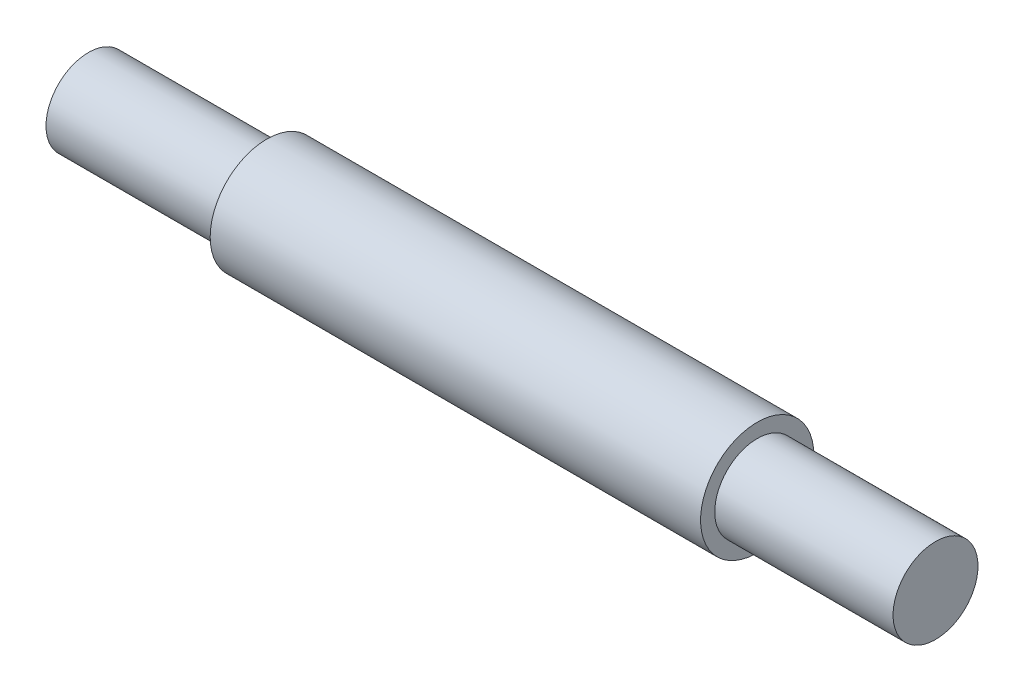
from build123d import *

# Parameters (mm, degrees)
SKETCH1_R                = 6.35
BOSS_EXTRUDE1_DEPTH      = 55
BOSS_EXTRUDE1_DEPTH_BACK = 40
SKETCH2_OUTSIDE_W        = 34.036
SKETCH2_OUTSIDE_H        = 34.036
SKETCH2_OUTSIDE_R        = 4.7625
CUT_EXTRUDE1_DEPTH       = 20
SKETCH3_OUTSIDE_W        = 34.036
SKETCH3_OUTSIDE_H        = 34.036
SKETCH3_OUTSIDE_R        = 4.7625
CUT_EXTRUDE2_DEPTH       = 20


with BuildPart() as part:
    # Sketch1 → Boss-Extrude1 (new body, two sides)
    with BuildSketch(Plane(origin=(0, 0, 0), x_dir=(0, 0, -1), z_dir=(1, 0, 0))) as boss_extrude1_sk:
        Circle(SKETCH1_R)
    extrude(amount=BOSS_EXTRUDE1_DEPTH)
    extrude(boss_extrude1_sk.sketch, amount=-BOSS_EXTRUDE1_DEPTH_BACK)

    # Sketch2 outside → Cut-Extrude1 (cut)
    with BuildSketch(Plane.ZY.offset(40)):
        Rectangle(SKETCH2_OUTSIDE_W, SKETCH2_OUTSIDE_H)
        Circle(SKETCH2_OUTSIDE_R, mode=Mode.SUBTRACT)
    extrude(amount=-CUT_EXTRUDE1_DEPTH, mode=Mode.SUBTRACT)

    # Sketch3 outside → Cut-Extrude2 (cut)
    with BuildSketch(Plane(origin=(55, 0, 0), x_dir=(0, 0, -1), z_dir=(1, 0, 0))):
        Rectangle(SKETCH3_OUTSIDE_W, SKETCH3_OUTSIDE_H)
        Circle(SKETCH3_OUTSIDE_R, mode=Mode.SUBTRACT)
    extrude(amount=-CUT_EXTRUDE2_DEPTH, mode=Mode.SUBTRACT)


solid = part.part
